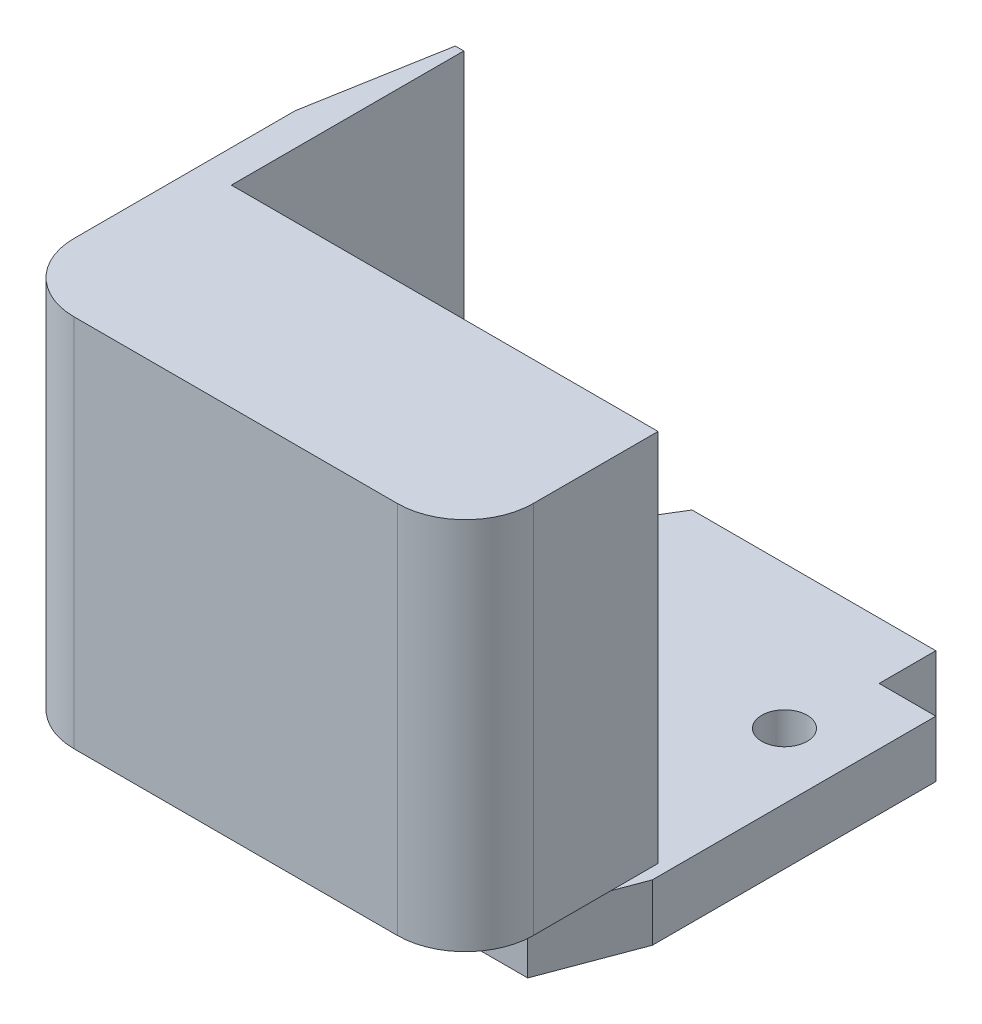
from build123d import *

# Parameters (mm, degrees)
BOSS_EXTRUDE1_DEPTH = 10
CHAMFER1_SIZE       = 6
CHAMFER1_SIZE2      = 16
CHAMFER2_SIZE       = 16
CHAMFER2_SIZE2      = 6
SKETCH2_W           = 10
SKETCH2_H           = 10
CUT_EXTRUDE1_DEPTH  = 10
BOSS_EXTRUDE2_DEPTH = 7
SKETCH4_R           = 5
SKETCH4_R_2         = 4.7
CUT_EXTRUDE2_DEPTH  = 3
SKETCH5_R           = 2.15
CUT_EXTRUDE3_DEPTH  = 11
SKETCH6_R           = 4
CUT_EXTRUDE4_DEPTH  = 6
SKETCH7_R           = 2.4
BOSS_EXTRUDE3_DEPTH = 4.6
SKETCH8_R           = 1.65
CUT_EXTRUDE5_DEPTH  = 10
BOSS_EXTRUDE4_DEPTH = 66


with BuildPart() as part:
    # Sketch1 → Boss-Extrude1 (new body)
    with BuildSketch(Plane(origin=(0, 0, 0), x_dir=(1, 0, 0), z_dir=(0, 1, 0))):
        Polygon((0, 0), (0, -45), (86, -45), (86, 31), (33, 31), (14, 0), align=None)
    extrude(amount=BOSS_EXTRUDE1_DEPTH)

    # Chamfer1
    chamfer1_edges = [part.edges().sort_by_distance(p)[0] for p in [
        (86, 5, 45),
    ]]
    chamfer1_side = [part.faces().sort_by_distance(p)[0] for p in [
        (43, 5, 45),
    ]]
    chamfer(chamfer1_edges, length=CHAMFER1_SIZE, length2=CHAMFER1_SIZE2, reference=chamfer1_side[0])

    # Chamfer2
    chamfer2_edges = [part.edges().sort_by_distance(p)[0] for p in [
        (0, 5, 45),
    ]]
    chamfer2_side = [part.faces().sort_by_distance(p)[0] for p in [
        (0, 5, 22.5),
    ]]
    chamfer(chamfer2_edges, length=CHAMFER2_SIZE, length2=CHAMFER2_SIZE2, reference=chamfer2_side[0])

    # Sketch2 → Cut-Extrude1 (cut)
    with BuildSketch(Plane(origin=(0, 10, 0), x_dir=(1, 0, 0), z_dir=(0, 1, 0))):
        with Locations((81, 26)):
            Rectangle(SKETCH2_W, SKETCH2_H)
    extrude(amount=-CUT_EXTRUDE1_DEPTH, mode=Mode.SUBTRACT)

    # Sketch3 → Boss-Extrude2 (add)
    with BuildSketch(Plane.XZ):
        with BuildLine():
            Line((44.7, 2.297872822), (44.7, 11.702127178))
            ThreePointArc((44.7, 11.702127178), (43, 12), (41.3, 11.702127178))
            Line((41.3, 11.702127178), (41.3, 2.297872822))
            ThreePointArc((41.3, 2.297872822), (43, 2), (44.7, 2.297872822))
        make_face()
    extrude(amount=BOSS_EXTRUDE2_DEPTH)

    # Sketch4 → Cut-Extrude2 (cut)
    with BuildSketch(Plane.XZ.offset(7)):
        with Locations((43, 7)):
            Circle(SKETCH4_R)
        with Locations((43, 7)):
            Circle(SKETCH4_R_2, mode=Mode.SUBTRACT)
    extrude(amount=-CUT_EXTRUDE2_DEPTH, mode=Mode.SUBTRACT)

    # Sketch5 → Cut-Extrude3 (cut, through all)
    with BuildSketch(Plane.XZ):
        with Locations((74.5, 35.5)):
            Circle(SKETCH5_R)
        with Locations((11, 35.5)):
            Circle(SKETCH5_R)
        with Locations((74.5, -5.8)):
            Circle(SKETCH5_R)
    extrude(amount=-CUT_EXTRUDE3_DEPTH, mode=Mode.SUBTRACT)

    # Sketch6 → Cut-Extrude4 (cut)
    with BuildSketch(Plane(origin=(0, 10, 0), x_dir=(1, 0, 0), z_dir=(0, 1, 0))):
        with Locations((74.5, 5.8)):
            Circle(SKETCH6_R)
        with Locations((74.5, -35.5)):
            Circle(SKETCH6_R)
        with Locations((11, -35.5)):
            Circle(SKETCH6_R)
    extrude(amount=-CUT_EXTRUDE4_DEPTH, mode=Mode.SUBTRACT)

    # Sketch7 → Boss-Extrude3 (add)
    with BuildSketch(Plane.XZ):
        with Locations((61.4, 7)):
            Circle(SKETCH7_R)
        with Locations((24.6, 7)):
            Circle(SKETCH7_R)
    extrude(amount=BOSS_EXTRUDE3_DEPTH)

    # Sketch8 → Cut-Extrude5 (cut)
    with BuildSketch(Plane(origin=(0, 0, -31), x_dir=(-1, 0, 0), z_dir=(0, 0, -1))):
        with Locations((-43, 5)):
            Circle(SKETCH8_R)
    extrude(amount=-CUT_EXTRUDE5_DEPTH, mode=Mode.SUBTRACT)

    # Sketch10 → Boss-Extrude4 (add)
    with BuildSketch(Plane(origin=(0, 10, 0), x_dir=(1, 0, 0), z_dir=(0, 1, 0))):
        with BuildLine():
            Line((15, -60), (72, -60))
            ThreePointArc((72, -60), (80.485281374, -56.485281374), (84, -48))
            Line((84, -48), (84, -26))
            Line((84, -26), (8.731847537, -26))
            Line((8.731847537, -26), (8.731847537, 15))
            Line((8.731847537, 15), (7.231847537, 15))
            Line((7.231847537, 15), (3, -9))
            Line((3, -9), (3, -48))
            ThreePointArc((3, -48), (6.514718626, -56.485281374), (15, -60))
        make_face()
    extrude(amount=BOSS_EXTRUDE4_DEPTH)


solid = part.part
